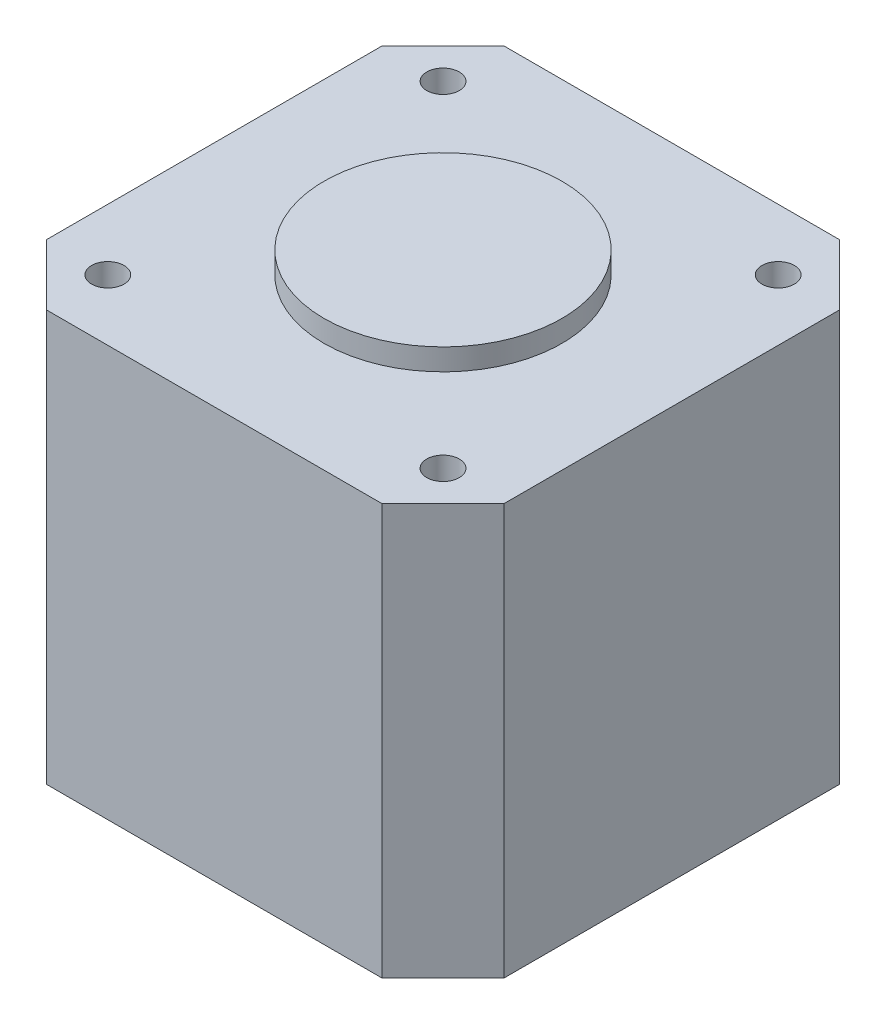
from build123d import *

# Parameters (mm, degrees)
EXTRUDE_1_DEPTH     = 38
SKETCH_3_R          = 11
EXTRUDE_2_DEPTH     = 2
SKETCH_15_R         = 1.5
CUT_EXTRUDE_1_DEPTH = 5


with BuildPart() as part:
    # 草图2 → 凸台-拉伸1 (new body)
    with BuildSketch(Plane(origin=(0, 0, 0), x_dir=(1, 0, 0), z_dir=(0, 1, 0))):
        Polygon((-15.5, 21.15), (-21.15, 15.5), (-21.15, -15.5), (-15.5, -21.15), (15.5, -21.15), (21.15, -15.5), (21.15, 15.5), (15.5, 21.15), align=None)
    extrude(amount=EXTRUDE_1_DEPTH)

    # 草图3 → 凸台-拉伸2 (add)
    with BuildSketch(Plane(origin=(0, 38, 0), x_dir=(1, 0, 0), z_dir=(0, 1, 0))):
        Circle(SKETCH_3_R)
    extrude(amount=EXTRUDE_2_DEPTH)

    # 草图15 → 切除-拉伸1 (cut)
    with BuildSketch(Plane(origin=(0, 38, 0), x_dir=(1, 0, 0), z_dir=(0, 1, 0))):
        with Locations((-15.5, 15.5)):
            Circle(SKETCH_15_R)
        with Locations((15.5, 15.5)):
            Circle(SKETCH_15_R)
        with Locations((15.5, -15.5)):
            Circle(SKETCH_15_R)
        with Locations((-15.5, -15.5)):
            Circle(SKETCH_15_R)
    extrude(amount=-CUT_EXTRUDE_1_DEPTH, mode=Mode.SUBTRACT)


solid = part.part
